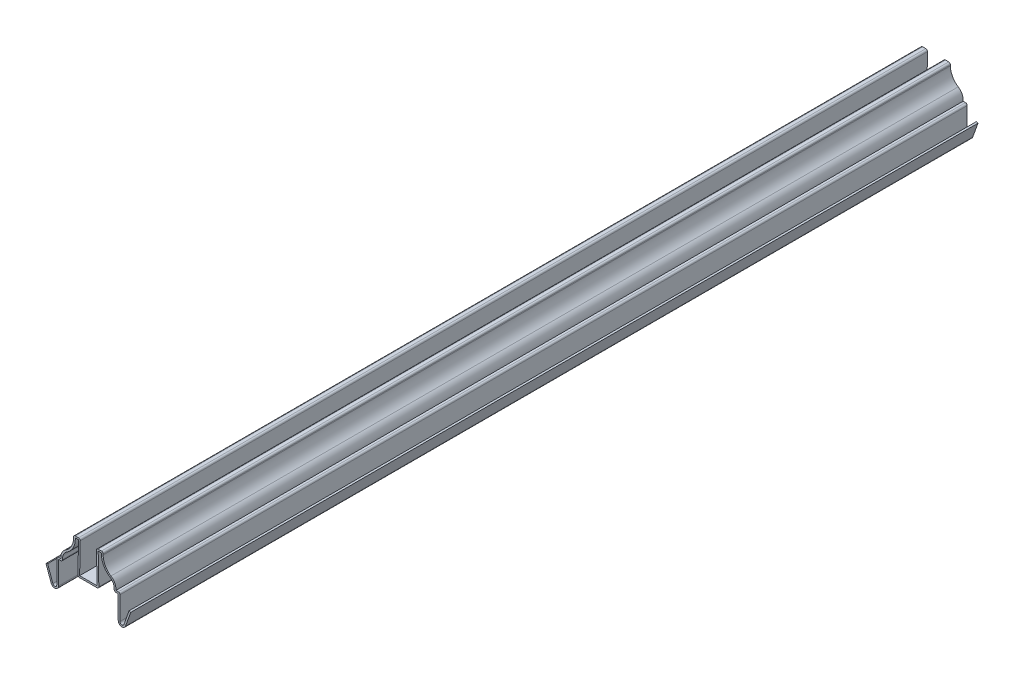
from build123d import *

# Parameters (mm, degrees)
EXTRUDE_THIN1_DEPTH = 500.0625
FILLET1_R           = 1.016


with BuildPart() as part:
    # Sketch1 → Extrude-Thin1 (new body)
    with BuildSketch(Plane.XY):
        with BuildLine():
            Line((-24.046802967, -1.731966596), (-20.964439882, -10.323922359))
            ThreePointArc((-20.964439882, -10.323922359), (-19.639707725, -11.09488593), (-18.653125, -9.921875))
            Line((-18.653125, -9.921875), (-18.653125, 4.7625))
            Line((-18.653125, 4.7625), (-16.247439028, 4.7625))
            ThreePointArc((-16.247439028, 4.7625), (-15.61651691, 8.128589514), (-13.329192073, 10.677465037))
            ThreePointArc((-13.329192073, 10.677465037), (-9.956372718, 14.274007616), (-8.73125, 19.05))
            Line((-8.73125, 19.05), (-8.73125, 20.6375))
            Line((-8.73125, 20.6375), (-4.7625, 20.6375))
            Line((-4.7625, 20.6375), (-5.159375, 1.5875))
            Line((-5.159375, 1.5875), (5.159375, 1.5875))
            Line((5.159375, 1.5875), (4.7625, 20.6375))
            Line((4.7625, 20.6375), (8.73125, 20.6375))
            Line((8.73125, 20.6375), (8.73125, 19.05))
            ThreePointArc((8.73125, 19.05), (9.956372718, 14.274007616), (13.329192073, 10.677465037))
            ThreePointArc((13.329192073, 10.677465037), (15.61651691, 8.128589514), (16.247439028, 4.7625))
            Line((16.247439028, 4.7625), (18.653125, 4.7625))
            Line((18.653125, 4.7625), (18.653125, -9.921875))
            ThreePointArc((18.653125, -9.921875), (19.639707725, -11.09488593), (20.964439882, -10.323922359))
            Line((20.964439882, -10.323922359), (24.046802967, -1.731966596))
            Line((24.046802967, -1.731966596), (25.003125, -2.075047009))
            Line((25.003125, -2.075047009), (21.920761915, -10.667002772))
            ThreePointArc((21.920761915, -10.667002772), (19.465591651, -12.095855256), (17.637125, -9.921875))
            Line((17.637125, -9.921875), (17.637125, 3.7465))
            Line((17.637125, 3.7465), (15.018802072, 3.7465))
            ThreePointArc((15.018802072, 3.7465), (14.927763498, 7.160953719), (12.784021341, 9.820117457))
            ThreePointArc((12.784021341, 9.820117457), (9.065825284, 13.784945996), (7.71525, 19.05))
            Line((7.71525, 19.05), (7.71525, 19.6215))
            Line((7.71525, 19.6215), (5.799887129, 19.6215))
            Line((5.799887129, 19.6215), (6.196762129, 0.5715))
            Line((6.196762129, 0.5715), (-6.196762129, 0.5715))
            Line((-6.196762129, 0.5715), (-5.799887129, 19.6215))
            Line((-5.799887129, 19.6215), (-7.71525, 19.6215))
            Line((-7.71525, 19.6215), (-7.71525, 19.05))
            ThreePointArc((-7.71525, 19.05), (-9.065825284, 13.784945996), (-12.784021341, 9.820117457))
            ThreePointArc((-12.784021341, 9.820117457), (-14.927763498, 7.160953719), (-15.018802072, 3.7465))
            Line((-15.018802072, 3.7465), (-17.637125, 3.7465))
            Line((-17.637125, 3.7465), (-17.637125, -9.921875))
            ThreePointArc((-17.637125, -9.921875), (-19.465591651, -12.095855256), (-21.920761915, -10.667002772))
            Line((-21.920761915, -10.667002772), (-25.003125, -2.075047009))
            Line((-25.003125, -2.075047009), (-24.046802967, -1.731966596))
        make_face()
    extrude(amount=-EXTRUDE_THIN1_DEPTH)

    # Fillet1
    fillet1_edges = [part.edges().sort_by_distance(p)[0] for p in [
        (-18.653125, 4.7625, -250.03125),
        (-8.73125, 20.6375, -250.03125),
        (-4.7625, 20.6375, -250.03125),
        (4.7625, 20.6375, -250.03125),
        (8.73125, 20.6375, -250.03125),
        (18.653125, 4.7625, -250.03125),
        (15.018802072, 3.7465, -250.03125),
        (6.196762129, 0.5715, -250.03125),
        (-6.196762129, 0.5715, -250.03125),
        (-15.018802072, 3.7465, -250.03125),
    ]]
    fillet(fillet1_edges, radius=FILLET1_R)


solid = part.part
